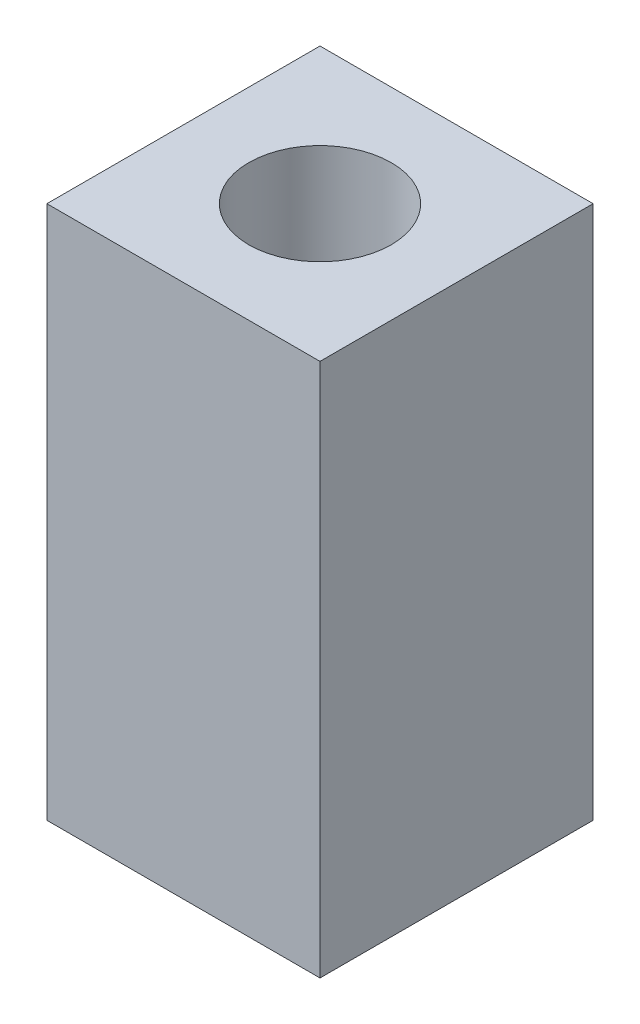
from build123d import *

# Parameters (mm, degrees)
SKETCH1_W           = 11.506907796
SKETCH1_H           = 11.506907796
SKETCH1_R           = 3
BOSS_EXTRUDE1_DEPTH = 22.5


with BuildPart() as part:
    # Sketch1 → Boss-Extrude1 (new body)
    with BuildSketch(Plane(origin=(0, 0, 0), x_dir=(1, 0, 0), z_dir=(0, 1, 0))):
        Rectangle(SKETCH1_W, SKETCH1_H)
        Circle(SKETCH1_R, mode=Mode.SUBTRACT)
    extrude(amount=BOSS_EXTRUDE1_DEPTH)


solid = part.part
